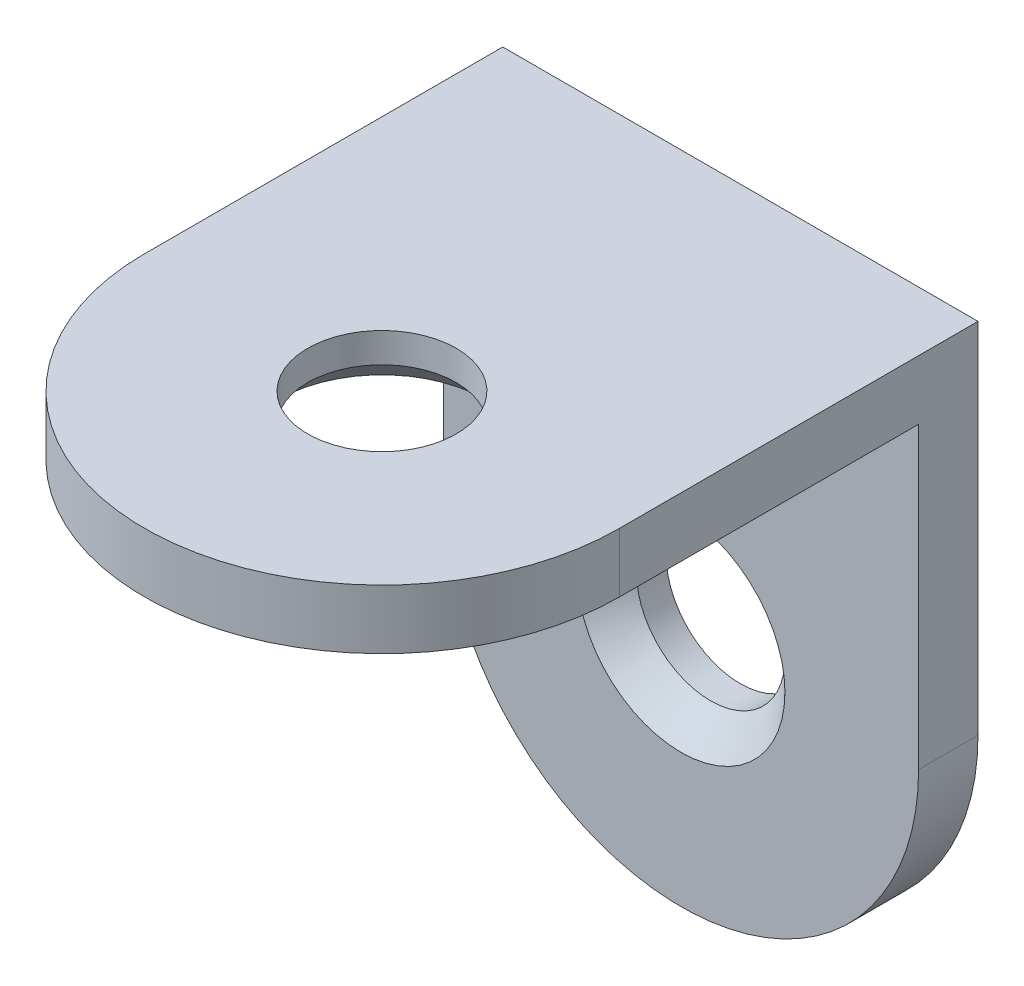
from build123d import *

# Parameters (mm, degrees)
BOSS_EXTRUDE1_DEPTH      = 8.001
BOSS_EXTRUDE1_DEPTH_BACK = 8.001
CUT_EXTRUDE1_DEPTH       = 8.001
CUT_EXTRUDE2_DEPTH       = 8.001
SKETCH5_R                = 2.5
CUT_EXTRUDE3_DEPTH       = 10
SKETCH6_R                = 2.5
CUT_EXTRUDE4_DEPTH       = 10
CHAMFER1_SIZE            = 1


with BuildPart() as part:
    # Sketch2 → Boss-Extrude1 (new, two sides: drawn at the far end of the back side and taken through both)
    with BuildSketch(Plane(origin=(0, 0, 0), x_dir=(0, 0, -1), z_dir=(1, 0, 0)).offset(-BOSS_EXTRUDE1_DEPTH_BACK)):
        Polygon((-20.07, 0), (0, 0), (0, -20.07), (-2, -20.07), (-2, -2), (-20.07, -2), align=None)
    extrude(amount=BOSS_EXTRUDE1_DEPTH + BOSS_EXTRUDE1_DEPTH_BACK)

    # Sketch3 → Cut-Extrude1 (cut)
    with BuildSketch(Plane.XZ.offset(2)):
        with BuildLine():
            Line((-8.001, 12.069), (-12.725932728, 12.069))
            Line((-12.725932728, 12.069), (-12.725932728, 24.915681473))
            Line((-12.725932728, 24.915681473), (12.141962569, 24.915681473))
            Line((12.141962569, 24.915681473), (12.141962569, 12.069))
            Line((12.141962569, 12.069), (8.001, 12.069))
            ThreePointArc((8.001, 12.069), (0, 20.07), (-8.001, 12.069))
        make_face()
    extrude(amount=-CUT_EXTRUDE1_DEPTH, mode=Mode.SUBTRACT)

    # Sketch4 → Cut-Extrude2 (cut)
    with BuildSketch(Plane.XY.offset(2)):
        with BuildLine():
            Line((-8.001, -12.069), (-10.480924408, -12.069))
            Line((-10.480924408, -12.069), (-10.480924408, -22.641723191))
            Line((-10.480924408, -22.641723191), (9.892967081, -22.641723191))
            Line((9.892967081, -22.641723191), (9.892967081, -12.069))
            Line((9.892967081, -12.069), (8.001, -12.069))
            ThreePointArc((8.001, -12.069), (0, -20.07), (-8.001, -12.069))
        make_face()
    extrude(amount=-CUT_EXTRUDE2_DEPTH, mode=Mode.SUBTRACT)

    # Sketch5 → Cut-Extrude3 (cut)
    with BuildSketch(Plane.XY.offset(2)):
        with Locations((0, -12.069)):
            Circle(SKETCH5_R)
    extrude(amount=-CUT_EXTRUDE3_DEPTH, mode=Mode.SUBTRACT)

    # Sketch6 → Cut-Extrude4 (cut)
    with BuildSketch(Plane.XZ.offset(2)):
        with Locations((0, 12.069)):
            Circle(SKETCH6_R)
    extrude(amount=-CUT_EXTRUDE4_DEPTH, mode=Mode.SUBTRACT)

    # Chamfer1
    chamfer1_edges = [part.edges().sort_by_distance(p)[0] for p in [
        (-2.5, -2, 12.069),
        (-2.5, -12.069, 2),
    ]]
    chamfer(chamfer1_edges, length=CHAMFER1_SIZE)


solid = part.part
